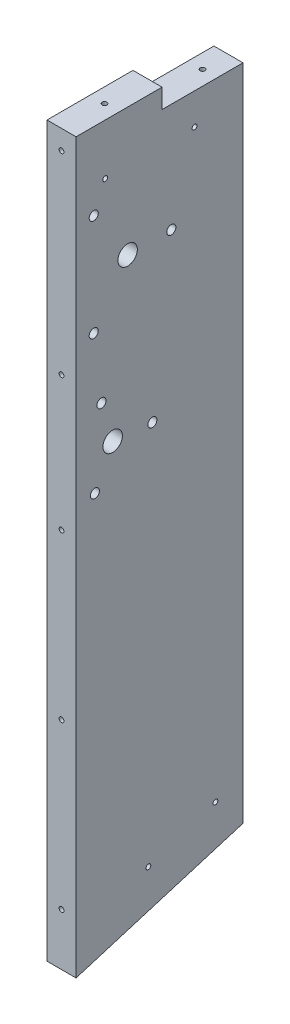
from build123d import *

# Parameters (mm, degrees)
SKETCH1_W                        = 19.05
SKETCH1_H                        = 427.342121692
BOSS_EXTRUDE1_DEPTH              = 53
SKETCH2_W                        = 19.05
SKETCH2_H                        = 440.042121692
BOSS_EXTRUDE2_DEPTH              = 56.3
BOSS_EXTRUDE3_DEPTH              = 19.05
F_15_64_0_23438_DIAMETER_HOLE1_D = 5.953252
SKETCH4_R                        = 6.35
CUT_EXTRUDE1_DEPTH               = 20.05
HOLE1_D                          = 3.175
HOLE1_DEPTH                      = 31.75
HOLE1_CSINK_D                    = 10.16
HOLE1_CSINK_ANGLE                = 82
HOLE1_TIP                        = 0.953866233
HOLE_D                           = 3.175
HOLE_DEPTH                       = 31.75
HOLE_CSINK_D                     = 10.16
HOLE_CSINK_ANGLE                 = 82
HOLE_TIP                         = 0.953866233
HOLE3_D                          = 3.175
HOLE3_DEPTH                      = 31.75
HOLE3_CSINK_D                    = 10.16
HOLE3_CSINK_ANGLE                = 82
HOLE3_TIP                        = 0.953866233
HOLE4_D                          = 3.175
HOLE4_DEPTH                      = 31.75
HOLE4_CSINK_D                    = 10.16
HOLE4_CSINK_ANGLE                = 82
HOLE4_TIP                        = 0.953866233
HOLE5_D                          = 3.175
HOLE5_DEPTH                      = 31.75
HOLE5_CSINK_D                    = 10.16
HOLE5_CSINK_ANGLE                = 82
HOLE5_TIP                        = 0.953866233
HOLE6_D                          = 3.175
HOLE6_DEPTH                      = 31.75
HOLE6_CSINK_D                    = 10.16
HOLE6_CSINK_ANGLE                = 82
HOLE6_TIP                        = 0.953866233


with BuildPart() as part:
    # Sketch1 → Boss-Extrude1 (new body)
    with BuildSketch(Plane.XY):
        with Locations((-331.779465963, -213.671060846)):
            Rectangle(SKETCH1_W, SKETCH1_H)
    extrude(amount=BOSS_EXTRUDE1_DEPTH)

    # Sketch2 → Boss-Extrude2 (add)
    with BuildSketch(Plane.XY.offset(53)):
        with Locations((-331.779465963, -207.321060846)):
            Rectangle(SKETCH2_W, SKETCH2_H)
    extrude(amount=BOSS_EXTRUDE2_DEPTH)

    # Sketch3 → Boss-Extrude3 (add, through all)
    with BuildSketch(Plane.ZY.offset(341.304465963)):
        Polygon((0, -427.342121692), (109.3, -427.342121692), (109.3, -464.26606302), (0, -431.185843453), align=None)
    extrude(amount=-BOSS_EXTRUDE3_DEPTH)

    # 15/64 (0.23438) Diameter Hole1 (through all)
    with Locations(Plane.ZY.offset(341.304465963)):
        with Locations((97.748316108, -37.83597394), (97.748316108, -104.51097394), (46.948316108, -71.17347394), (92.682630332, -146.588148739), (96.973742428, -195.635784431), (59.351224796, -174.21579854)):
            Hole(F_15_64_0_23438_DIAMETER_HOLE1_D / 2)

    # Sketch4 → Cut-Extrude1 (cut, through all)
    with BuildSketch(Plane.ZY.offset(341.304465963)):
        with Locations((75.523316108, -71.17347394)):
            Circle(SKETCH4_R)
        with Locations((85.33943188, -171.942125034)):
            Circle(SKETCH4_R)
    extrude(amount=-CUT_EXTRUDE1_DEPTH, mode=Mode.SUBTRACT)

    # Hole1
    with Locations(Plane(origin=(-124.004465969, 10.424290059, 122), x_dir=(-1, 0, 0), z_dir=(0, 0, 1))):
        with Locations((113.649999994, 128.807623392), (113.649999994, 23.940956725), (-94.599999994, 161.374290059), (94.599999994, 161.374290059), (0, 161.374290059), (0, 193.124290059), (0, 440.553783621), (0, 301.970350905), (40.979166666, 301.970350905), (166.795833328, 301.970350905), (207.774999994, 440.553783621), (207.774999994, 333.02141023), (207.774999994, 225.48903684), (207.774999994, 137.424290059), (207.774999994, 10.424290059), (-207.774999994, 10.424290059), (-207.774999994, 137.424290059), (-207.774999994, 225.48903684), (-207.774999994, 333.02141023), (-207.774999994, 440.553783621), (-166.795833328, 301.970350905), (-40.979166666, 301.970350905), (-113.649999994, 23.940956725), (-113.649999994, 128.807623392)):
            CounterSinkHole(HOLE1_D / 2, HOLE1_CSINK_D / 2, depth=HOLE1_DEPTH, counter_sink_angle=HOLE1_CSINK_ANGLE)
            with Locations((0, 0, -(HOLE1_DEPTH + HOLE1_TIP / 2))):  # 118° drill point
                Cone(0, HOLE1_D / 2, HOLE1_TIP, mode=Mode.SUBTRACT)

    # Hole
    with Locations(Plane(origin=(-124.004465969, 25.4, -155.286738577), x_dir=(-1, 0, 0), z_dir=(0, 1, 0))):
        with Locations((113.649999994, 236.436738577), (207.774999994, 236.436738577)):
            CounterSinkHole(HOLE_D / 2, HOLE_CSINK_D / 2, depth=HOLE_DEPTH, counter_sink_angle=HOLE_CSINK_ANGLE)
            with Locations((0, 0, -(HOLE_DEPTH + HOLE_TIP / 2))):  # 118° drill point
                Cone(0, HOLE_D / 2, HOLE_TIP, mode=Mode.SUBTRACT)

    # Hole3
    with Locations(Plane(origin=(-124.004465969, 12.7, -155.286738577), x_dir=(-1, 0, 0), z_dir=(0, 1, 0))):
        with Locations((207.774999994, 172.261738577), (126.349999994, 172.261738577)):
            CounterSinkHole(HOLE3_D / 2, HOLE3_CSINK_D / 2, depth=HOLE3_DEPTH, counter_sink_angle=HOLE3_CSINK_ANGLE)
            with Locations((0, 0, -(HOLE3_DEPTH + HOLE3_TIP / 2))):  # 118° drill point
                Cone(0, HOLE3_D / 2, HOLE3_TIP, mode=Mode.SUBTRACT)

    # Hole4
    with Locations(Plane(origin=(-124.004465969, 10.424290059, -12.7), x_dir=(1, 0, 0), z_dir=(0, 0, -1))):
        with Locations((-207.774999994, 333.02141023), (-207.774999994, 225.48903684), (-207.774999994, 137.424290059), (-172.166666661, 4.074290059), (-146.083333327, 4.074290059), (-94.599999994, 161.374290059), (0, 161.374290059), (94.599999994, 161.374290059), (146.083333327, 4.074290059), (172.166666661, 4.074290059), (207.774999994, 137.424290059), (207.774999994, 225.48903684), (207.774999994, 333.02141023), (166.795833328, 301.970350905), (40.979166666, 301.970350905), (-40.979166666, 301.970350905), (-166.795833328, 301.970350905), (0, 193.124290059), (0, 301.970350905), (0, 412.366411751), (-126.349999994, 106.824290059), (-126.349999994, 58.624290059), (126.349999994, 58.624290059), (126.349999994, 106.824290059)):
            CounterSinkHole(HOLE4_D / 2, HOLE4_CSINK_D / 2, depth=HOLE4_DEPTH, counter_sink_angle=HOLE4_CSINK_ANGLE)
            with Locations((0, 0, -(HOLE4_DEPTH + HOLE4_TIP / 2))):  # 118° drill point
                Cone(0, HOLE4_D / 2, HOLE4_TIP, mode=Mode.SUBTRACT)

    # Hole5
    with Locations(Plane(origin=(-124.004465969, -363.229637966, -268.375064111), x_dir=(1, 0, 0), z_dir=(0, -0.957123977, -0.289678603))):
        with Locations((207.774999994, 613.051808534), (-207.774999994, 613.051808534), (-207.774999994, 456.277103296), (-207.774999994, 769.826513772), (-108.649999997, 456.277103296), (-108.649999997, 630.126513772), (-108.649999997, 769.826513772), (-207.774999994, 362.200879148), (-207.774999994, 305.10273792), (0, 305.10273792), (0, 362.200879148), (207.774999994, 305.10273792), (207.774999994, 362.200879148), (108.649999997, 769.826513772), (108.649999997, 630.126513772), (108.649999997, 456.277103296), (207.774999994, 769.826513772), (207.774999994, 456.277103296)):
            CounterSinkHole(HOLE5_D / 2, HOLE5_CSINK_D / 2, depth=HOLE5_DEPTH, counter_sink_angle=HOLE5_CSINK_ANGLE)
            with Locations((0, 0, -(HOLE5_DEPTH + HOLE5_TIP / 2))):  # 118° drill point
                Cone(0, HOLE5_D / 2, HOLE5_TIP, mode=Mode.SUBTRACT)

    # Hole6
    with Locations(Plane(origin=(-354.004465963, 10.424290059, -155.286738577), x_dir=(0, -0.995945413, 0.089959629), z_dir=(-1, 0, 0))):
        with Locations((637.870011036, 553.595098153), (52.960474704, 241.752641108), (47.697836423, 183.489834462), (434.459074831, 134.806234549), (453.103621196, 177.188747915), (478.414399376, 275.292665941), (488.870508314, 435.756794718), (636.071223534, 609.111420407), (609.449424187, 543.22015483), (559.371199386, 359.303721429), (507.038658285, 229.776136946)):
            CounterSinkHole(HOLE6_D / 2, HOLE6_CSINK_D / 2, depth=HOLE6_DEPTH, counter_sink_angle=HOLE6_CSINK_ANGLE)
            with Locations((0, 0, -(HOLE6_DEPTH + HOLE6_TIP / 2))):  # 118° drill point
                Cone(0, HOLE6_D / 2, HOLE6_TIP, mode=Mode.SUBTRACT)


solid = part.part
